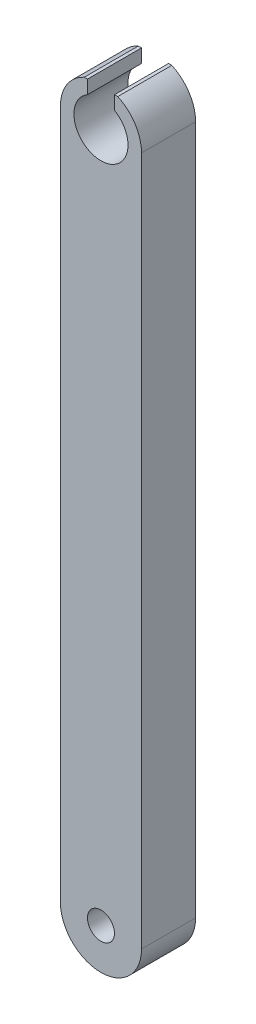
from build123d import *

# Parameters (mm, degrees)
SKETCH_1_R          = 0.5
EXTRUDE_1_DEPTH     = 2
CUT_EXTRUDE_1_DEPTH = 10


with BuildPart() as part:
    # 草图1 → 凸台-拉伸1 (new body)
    with BuildSketch(Plane.XY):
        with BuildLine():
            Line((-1.5, 25.5), (-1.5, 0))
            ThreePointArc((-1.5, 0), (0, -1.5), (1.5, 0))
            Line((1.5, 0), (1.5, 25.5))
            ThreePointArc((1.5, 25.5), (0, 27), (-1.5, 25.5))
        make_face()
        Circle(SKETCH_1_R, mode=Mode.SUBTRACT)
    extrude(amount=EXTRUDE_1_DEPTH)

    # 草图2 → 切除-拉伸1 (cut)
    with BuildSketch(Plane.XY.offset(2)):
        with BuildLine():
            Line((-0.5, 26.866025404), (-0.5, 26.366025404))
            ThreePointArc((-0.5, 26.366025404), (0, 24.5), (0.5, 26.366025404))
            Line((0.5, 26.366025404), (0.5, 26.866025404))
            Line((0.5, 26.866025404), (0.619656837, 26.866025404))
            ThreePointArc((0.619656837, 26.866025404), (0, 27), (-0.619656837, 26.866025404))
            Line((-0.619656837, 26.866025404), (-0.5, 26.866025404))
        make_face()
    extrude(amount=-CUT_EXTRUDE_1_DEPTH, mode=Mode.SUBTRACT)


solid = part.part
